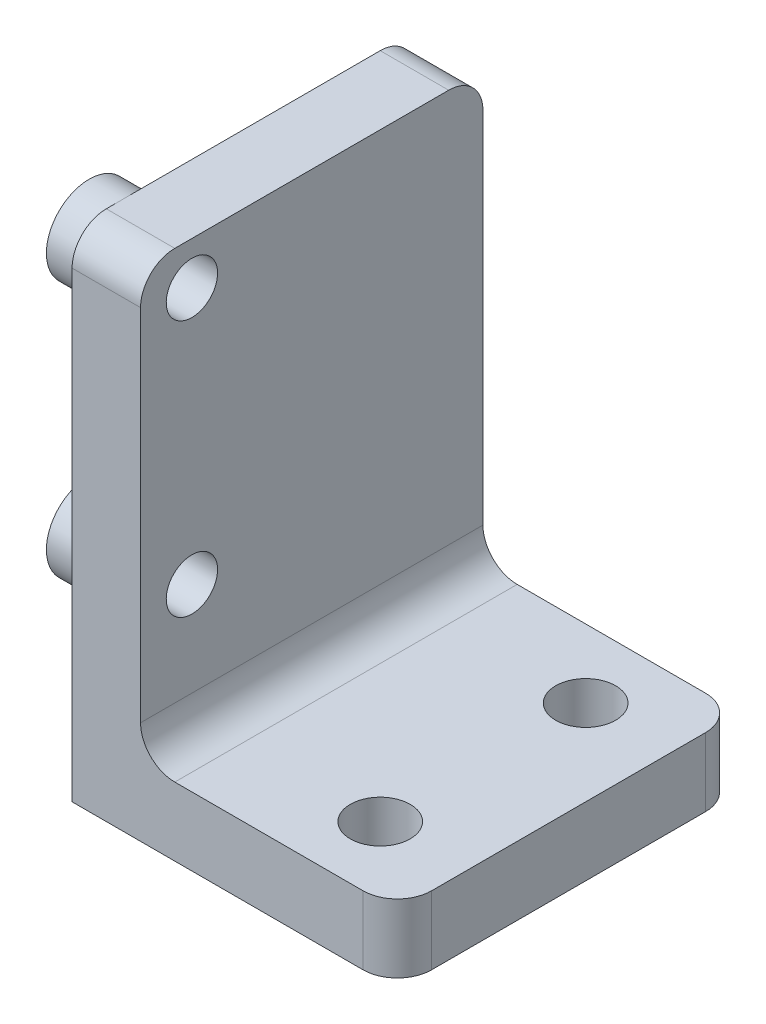
from build123d import *

# Parameters (mm, degrees)
BOSS_EXTRUDE1_DEPTH = 20
SKETCH2_R           = 1.5
CUT_EXTRUDE1_DEPTH  = 20
SKETCH3_R           = 1.75
CUT_EXTRUDE2_DEPTH  = 5
FILLET1_R           = 2
BOSS_EXTRUDE2_START = -4
SKETCH4_R           = 2.5
SKETCH4_R_2         = 1.5
BOSS_EXTRUDE2_DEPTH = 2


with BuildPart() as part:
    # Sketch1 → Boss-Extrude1 (new body)
    with BuildSketch(Plane.XY):
        Polygon((0, 0), (0, 29), (4, 29), (4, 4), (19, 4), (19, 0), align=None)
    extrude(amount=BOSS_EXTRUDE1_DEPTH)

    # Sketch2 → Cut-Extrude1 (cut, through all)
    with BuildSketch(Plane.ZY):
        with Locations((17, 26.5)):
            Circle(SKETCH2_R)
        with Locations((17, 11.5)):
            Circle(SKETCH2_R)
    extrude(amount=-CUT_EXTRUDE1_DEPTH, mode=Mode.SUBTRACT)

    # Sketch3 → Cut-Extrude2 (cut, through all)
    with BuildSketch(Plane(origin=(0, 4, 0), x_dir=(1, 0, 0), z_dir=(0, 1, 0))):
        with Locations((14, -4)):
            Circle(SKETCH3_R)
        with Locations((14, -16)):
            Circle(SKETCH3_R)
    extrude(amount=-CUT_EXTRUDE2_DEPTH, mode=Mode.SUBTRACT)

    # Fillet1
    fillet1_edges = [part.edges().sort_by_distance(p)[0] for p in [
        (4, 4, 10),
        (2, 29, 20),
        (2, 29, 0),
        (19, 2, 0),
        (19, 2, 20),
    ]]
    fillet(fillet1_edges, radius=FILLET1_R)

    # Sketch4 → Boss-Extrude2 (add)
    with BuildSketch(Plane(origin=(4, 0, 0), x_dir=(0, 0, -1), z_dir=(1, 0, 0)).offset(BOSS_EXTRUDE2_START)):
        with Locations((-17, 26.5)):
            Circle(SKETCH4_R)
        with Locations((-17, 26.5)):
            Circle(SKETCH4_R_2, mode=Mode.SUBTRACT)
        with Locations((-17, 11.5)):
            Circle(SKETCH4_R)
        with Locations((-17, 11.5)):
            Circle(SKETCH4_R_2, mode=Mode.SUBTRACT)
    extrude(amount=-BOSS_EXTRUDE2_DEPTH)


solid = part.part
